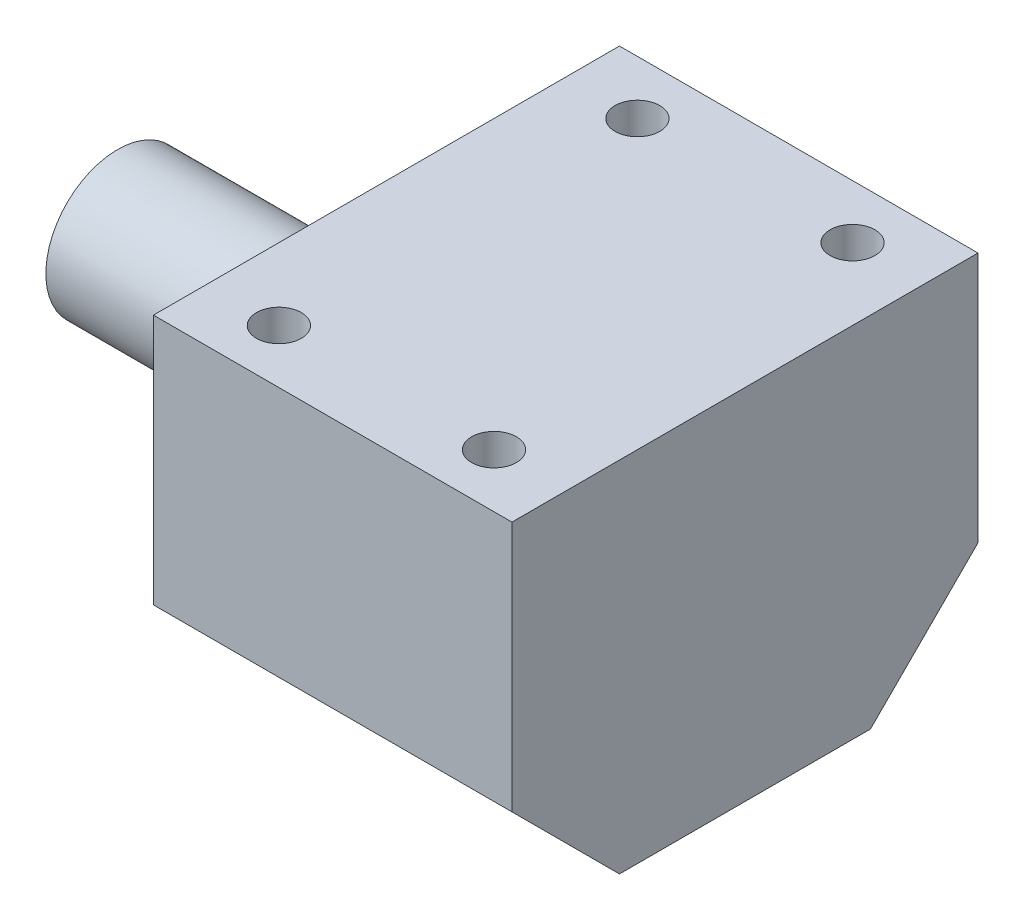
from build123d import *

# Parameters (mm, degrees)
SKETCH1_R           = 8
BOSS_EXTRUDE1_DEPTH = 150
SKETCH2_W           = 40
SKETCH2_H           = 52
BOSS_EXTRUDE2_DEPTH = 20
CHAMFER1_SIZE       = 12
SKETCH3_R           = 2.5
CUT_EXTRUDE1_DEPTH  = 10
SKETCH4_W           = 80.351410155
SKETCH4_H           = 105.979847546
CUT_EXTRUDE2_DEPTH  = 41


with BuildPart() as part:
    # Sketch1 → Boss-Extrude1 (new body)
    with BuildSketch(Plane(origin=(0, 0, 0), x_dir=(0, 0, -1), z_dir=(1, 0, 0))):
        Circle(SKETCH1_R)
    extrude(amount=BOSS_EXTRUDE1_DEPTH)

    # Sketch2 → Boss-Extrude2 (add, symmetric)
    with BuildSketch(Plane(origin=(0, 0, 0), x_dir=(1, 0, 0), z_dir=(0, 1, 0))):
        with Locations((50, 0)):
            Rectangle(SKETCH2_W, SKETCH2_H)
    extrude(amount=BOSS_EXTRUDE2_DEPTH, both=True)

    # Chamfer1
    chamfer1_edges = [part.edges().sort_by_distance(p)[0] for p in [
        (50, -20, 26),
        (50, -20, -26),
    ]]
    chamfer(chamfer1_edges, length=CHAMFER1_SIZE)

    # Sketch3 → Cut-Extrude1 (cut)
    with BuildSketch(Plane(origin=(0, 20, 0), x_dir=(1, 0, 0), z_dir=(0, 1, 0))):
        with Locations((38, 20)):
            Circle(SKETCH3_R)
        with Locations((62, 20)):
            Circle(SKETCH3_R)
        with Locations((38, -20)):
            Circle(SKETCH3_R)
        with Locations((62, -20)):
            Circle(SKETCH3_R)
    extrude(amount=-CUT_EXTRUDE1_DEPTH, mode=Mode.SUBTRACT)

    # Sketch4 → Cut-Extrude2 (cut, through all)
    with BuildSketch(Plane(origin=(0, 20, 0), x_dir=(1, 0, 0), z_dir=(0, 1, 0))):
        with Locations((110.175705077, -18.887237422)):
            Rectangle(SKETCH4_W, SKETCH4_H)
    extrude(amount=-CUT_EXTRUDE2_DEPTH, mode=Mode.SUBTRACT)


solid = part.part
